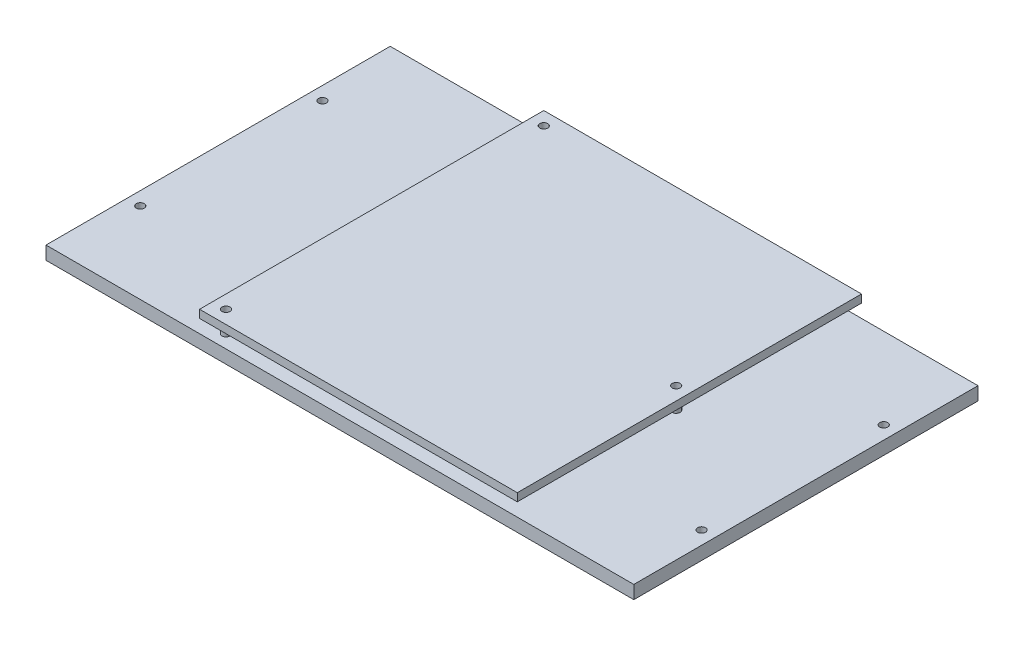
from build123d import *

# Parameters (mm, degrees)
ESBO_O1_W                = 222
ESBO_O1_H                = 130
ESBO_O1_R                = 1.5
RESSALTO_EXTRUS_O1_DEPTH = 5
ESBO_O2_R                = 1.5
RESSALTO_EXTRUS_O2_DEPTH = 5
RESSALTO_EXTRUS_O3_START = 5
ESBO_O2_3_W              = 120
ESBO_O2_3_H              = 130
ESBO_O2_3_R              = 1.5
RESSALTO_EXTRUS_O3_DEPTH = 3


with BuildPart() as part:
    # Esboço1 → Ressalto-extrusão1 (new body)
    with BuildSketch(Plane(origin=(0, 0, 0), x_dir=(1, 0, 0), z_dir=(0, 1, 0))):
        Rectangle(ESBO_O1_W, ESBO_O1_H)
        with Locations((-106, 34.4)):
            Circle(ESBO_O1_R, mode=Mode.SUBTRACT)
        with Locations((-106, -34.4)):
            Circle(ESBO_O1_R, mode=Mode.SUBTRACT)
        with Locations((106, 34.4)):
            Circle(ESBO_O1_R, mode=Mode.SUBTRACT)
        with Locations((106, -34.4)):
            Circle(ESBO_O1_R, mode=Mode.SUBTRACT)
    extrude(amount=RESSALTO_EXTRUS_O1_DEPTH)

    # Esboço2 → Ressalto-extrusão2 (add)
    with BuildSketch(Plane(origin=(0, 5, 0), x_dir=(1, 0, 0), z_dir=(0, 1, 0))):
        with Locations((-48, -60)):
            Circle(ESBO_O2_R)
        with Locations((62, 0)):
            Circle(ESBO_O2_R)
        with Locations((-48, 60)):
            Circle(ESBO_O2_R)
    extrude(amount=RESSALTO_EXTRUS_O2_DEPTH)


with BuildPart() as body_2:
    # Esboço2<3> → Ressalto-extrusão3 (new body)
    with BuildSketch(Plane(origin=(0, 5, 0), x_dir=(1, 0, 0), z_dir=(0, 1, 0)).offset(RESSALTO_EXTRUS_O3_START)):
        with Locations((7, 0)):
            Rectangle(ESBO_O2_3_W, ESBO_O2_3_H)
        with Locations((-48, -60)):
            Circle(ESBO_O2_3_R, mode=Mode.SUBTRACT)
        with Locations((62, 0)):
            Circle(ESBO_O2_3_R, mode=Mode.SUBTRACT)
        with Locations((-48, 60)):
            Circle(ESBO_O2_3_R, mode=Mode.SUBTRACT)
    extrude(amount=RESSALTO_EXTRUS_O3_DEPTH)


solid = Compound([part.part, body_2.part])
